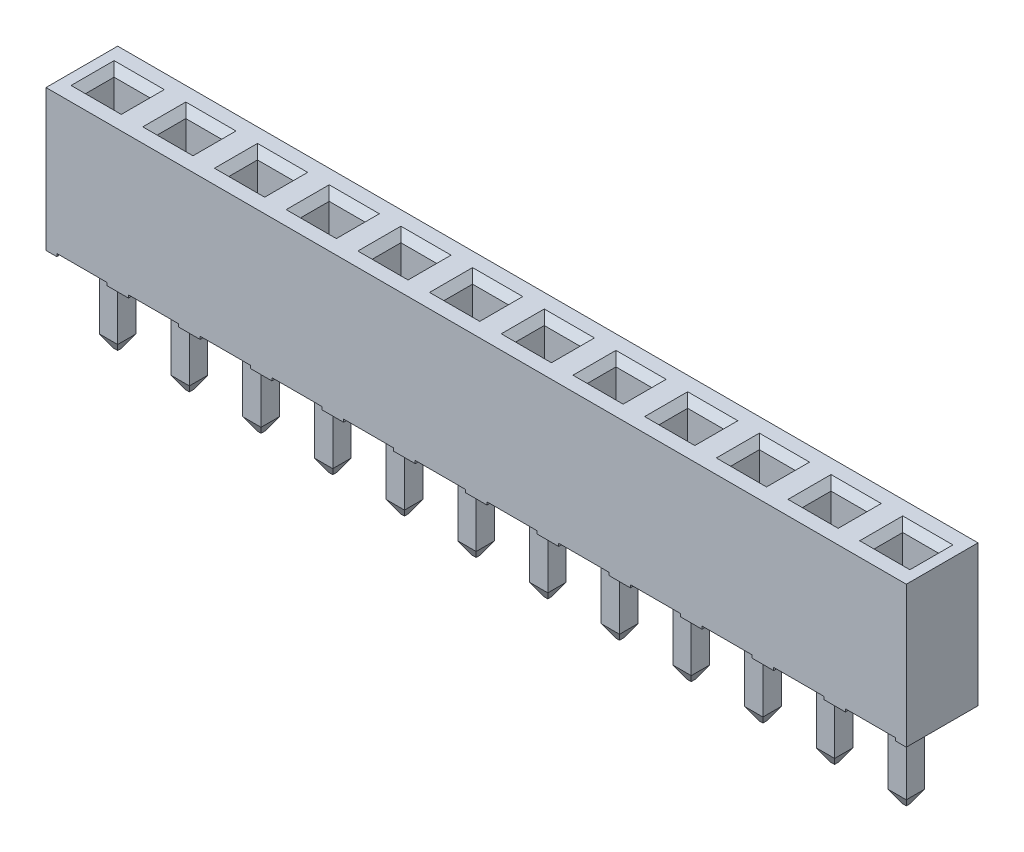
from build123d import *

# Parameters (mm, degrees)
SKETCH1_W                   = 2.54
SKETCH1_H                   = 2.54
BOSS_EXTRUDE1_DEPTH         = 4.9
SKETCH2_W                   = 1.27
SKETCH2_H                   = 1.016
CUT_EXTRUDE1_DEPTH          = 3.63
CHAMFER1_SIZE               = 0.254
SKETCH3_W                   = 0.381
SKETCH3_H                   = 2.54
BOSS_EXTRUDE2_DEPTH         = 0.1
SKETCH4_W                   = 0.65
SKETCH4_H                   = 0.65
BOSS_EXTRUDE3_DEPTH         = 3.1
CHAMFER2_SIZE               = 0.254
CHAMFER2_SIZE2              = 0.439940905
LPATTERN1_COUNT             = 12
LPATTERN1_PITCH             = 2.54
CHAMFER1_OF_LPATTERN1_SIZE  = 0.254
CHAMFER2_OF_LPATTERN1_SIZE2 = 0.254
CHAMFER2_OF_LPATTERN1_SIZE  = 0.439940905


with BuildPart() as part:
    # Sketch1 → Boss-Extrude1 (new body)
    with BuildSketch(Plane(origin=(0, 0, 0), x_dir=(1, 0, 0), z_dir=(0, 1, 0))):
        Rectangle(SKETCH1_W, SKETCH1_H)
    boss_extrude1 = extrude(amount=BOSS_EXTRUDE1_DEPTH)

    # Sketch2 → Cut-Extrude1 (cut)
    with BuildSketch(Plane(origin=(0, 4.9, 0), x_dir=(1, 0, 0), z_dir=(0, 1, 0))):
        Rectangle(SKETCH2_W, SKETCH2_H)
    cut_extrude1 = extrude(amount=-CUT_EXTRUDE1_DEPTH, mode=Mode.SUBTRACT)

    # Chamfer1
    chamfer1_edges = [part.edges().sort_by_distance(p)[0] for p in [
        (-0.635, 4.9, 0),
        (0, 4.9, 0.508),
        (0.635, 4.9, 0),
        (0, 4.9, -0.508),
    ]]
    chamfer(chamfer1_edges, length=CHAMFER1_SIZE)

    # Sketch3 → Boss-Extrude2 (add)
    with BuildSketch(Plane.XZ):
        with Locations((-1.0795, 0)):
            Rectangle(SKETCH3_W, SKETCH3_H)
        with Locations((1.0795, 0)):
            Rectangle(SKETCH3_W, SKETCH3_H)
    boss_extrude2 = extrude(amount=BOSS_EXTRUDE2_DEPTH)

    # Sketch4 → Boss-Extrude3 (add)
    with BuildSketch(Plane.XZ):
        Rectangle(SKETCH4_W, SKETCH4_H)
    boss_extrude3 = extrude(amount=BOSS_EXTRUDE3_DEPTH)

    # Chamfer2
    chamfer2_edges = [part.edges().sort_by_distance(p)[0] for p in [
        (0, -3.1, 0.325),
        (0.325, -3.1, 0),
        (0, -3.1, -0.325),
        (-0.325, -3.1, 0),
    ]]
    chamfer2_side = [part.faces().sort_by_distance(p)[0] for p in [
        (0, -3.1, 0),
    ]]
    chamfer(chamfer2_edges, length=CHAMFER2_SIZE, length2=CHAMFER2_SIZE2, reference=chamfer2_side[0])

    # LPattern1: Boss-Extrude1, Cut-Extrude1, Boss-Extrude2, Boss-Extrude3 ×12
    with Locations(*[(-i * LPATTERN1_PITCH, 0, 0) for i in range(1, LPATTERN1_COUNT)]):
        add(boss_extrude1)
        add(cut_extrude1, mode=Mode.SUBTRACT)
        add(boss_extrude2)
        add(boss_extrude3)

    # Chamfer1 of LPattern1
    chamfer1_of_lpattern1_edges = [part.edges().sort_by_distance(p)[0] for p in [
        (-3.175, 4.9, 0),
        (-2.54, 4.9, 0.508),
        (-1.905, 4.9, 0),
        (-2.54, 4.9, -0.508),
        (-5.715, 4.9, 0),
        (-5.08, 4.9, 0.508),
        (-4.445, 4.9, 0),
        (-5.08, 4.9, -0.508),
        (-8.255, 4.9, 0),
        (-7.62, 4.9, 0.508),
        (-6.985, 4.9, 0),
        (-7.62, 4.9, -0.508),
        (-10.795, 4.9, 0),
        (-10.16, 4.9, 0.508),
        (-9.525, 4.9, 0),
        (-10.16, 4.9, -0.508),
        (-13.335, 4.9, 0),
        (-12.7, 4.9, 0.508),
        (-12.065, 4.9, 0),
        (-12.7, 4.9, -0.508),
        (-15.875, 4.9, 0),
        (-15.24, 4.9, 0.508),
        (-14.605, 4.9, 0),
        (-15.24, 4.9, -0.508),
        (-18.415, 4.9, 0),
        (-17.78, 4.9, 0.508),
        (-17.145, 4.9, 0),
        (-17.78, 4.9, -0.508),
        (-20.955, 4.9, 0),
        (-20.32, 4.9, 0.508),
        (-19.685, 4.9, 0),
        (-20.32, 4.9, -0.508),
        (-23.495, 4.9, 0),
        (-22.86, 4.9, 0.508),
        (-22.225, 4.9, 0),
        (-22.86, 4.9, -0.508),
        (-26.035, 4.9, 0),
        (-25.4, 4.9, 0.508),
        (-24.765, 4.9, 0),
        (-25.4, 4.9, -0.508),
        (-28.575, 4.9, 0),
        (-27.94, 4.9, 0.508),
        (-27.305, 4.9, 0),
        (-27.94, 4.9, -0.508),
    ]]
    chamfer(chamfer1_of_lpattern1_edges, length=CHAMFER1_OF_LPATTERN1_SIZE)

    # Chamfer2 of LPattern1
    chamfer2_of_lpattern1_edges = [part.edges().sort_by_distance(p)[0] for p in [
        (-2.54, -3.1, 0.325),
        (-2.215, -3.1, 0),
        (-2.54, -3.1, -0.325),
        (-2.865, -3.1, 0),
        (-5.08, -3.1, 0.325),
        (-4.755, -3.1, 0),
        (-5.08, -3.1, -0.325),
        (-5.405, -3.1, 0),
        (-7.62, -3.1, 0.325),
        (-7.295, -3.1, 0),
        (-7.62, -3.1, -0.325),
        (-7.945, -3.1, 0),
        (-10.16, -3.1, 0.325),
        (-9.835, -3.1, 0),
        (-10.16, -3.1, -0.325),
        (-10.485, -3.1, 0),
        (-12.7, -3.1, 0.325),
        (-12.375, -3.1, 0),
        (-12.7, -3.1, -0.325),
        (-13.025, -3.1, 0),
        (-15.24, -3.1, 0.325),
        (-14.915, -3.1, 0),
        (-15.24, -3.1, -0.325),
        (-15.565, -3.1, 0),
        (-17.78, -3.1, 0.325),
        (-17.455, -3.1, 0),
        (-17.78, -3.1, -0.325),
        (-18.105, -3.1, 0),
        (-20.32, -3.1, 0.325),
        (-19.995, -3.1, 0),
        (-20.32, -3.1, -0.325),
        (-20.645, -3.1, 0),
        (-22.86, -3.1, 0.325),
        (-22.535, -3.1, 0),
        (-22.86, -3.1, -0.325),
        (-23.185, -3.1, 0),
        (-25.4, -3.1, 0.325),
        (-25.075, -3.1, 0),
        (-25.4, -3.1, -0.325),
        (-25.725, -3.1, 0),
        (-27.94, -3.1, 0.325),
        (-27.615, -3.1, 0),
        (-27.94, -3.1, -0.325),
        (-28.265, -3.1, 0),
    ]]
    chamfer(chamfer2_of_lpattern1_edges, length=CHAMFER2_OF_LPATTERN1_SIZE, length2=CHAMFER2_OF_LPATTERN1_SIZE2)


solid = part.part
